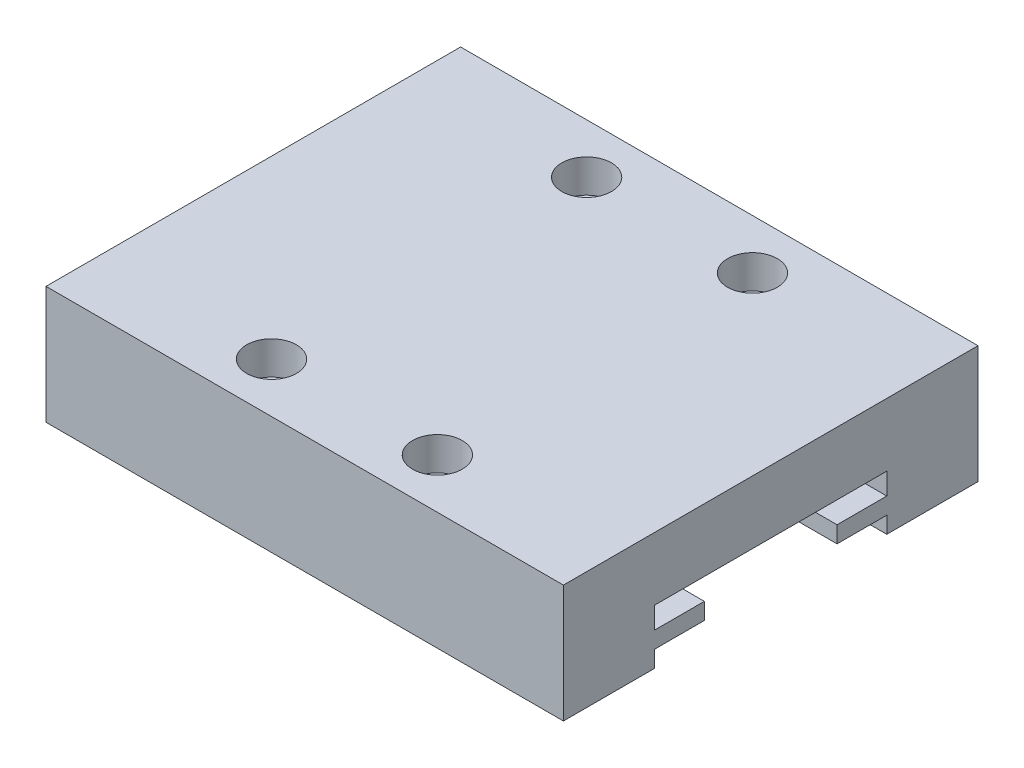
from build123d import *

# Parameters (mm, degrees)
SKETCH_1_W          = 31.2
SKETCH_1_H          = 25
EXTRUDE_1_DEPTH     = 7.1
CUT_EXTRUDE_1_DEPTH = 50.9
SKETCH_3_R          = 1.5
CUT_EXTRUDE_9_DEPTH = 2


with BuildPart() as part:
    # 草图1 → 凸台-拉伸1 (new body)
    with BuildSketch(Plane(origin=(0, 0, 0), x_dir=(1, 0, 0), z_dir=(0, 1, 0))):
        with Locations((15.6, 12.5)):
            Rectangle(SKETCH_1_W, SKETCH_1_H)
    extrude(amount=EXTRUDE_1_DEPTH)

    # 草图2 → 切除-拉伸1 (cut)
    with BuildSketch(Plane.ZY):
        Polygon((-19.5, 0), (-19.5, 1), (-16.5, 1), (-16.5, 2), (-19.5, 2), (-19.5, 3.3), (-12.5, 3.3), (-5.5, 3.3), (-5.5, 2), (-8.5, 2), (-8.5, 1), (-5.5, 1), (-5.5, 0), align=None)
    extrude(amount=-CUT_EXTRUDE_1_DEPTH, mode=Mode.SUBTRACT)

    # 草图3 → 切除-拉伸9 (cut)
    with BuildSketch(Plane(origin=(0, 7.1, 0), x_dir=(1, 0, 0), z_dir=(0, 1, 0))):
        with Locations((10.6, 22)):
            Circle(SKETCH_3_R)
        with Locations((20.6, 22)):
            Circle(SKETCH_3_R)
        with Locations((20.6, 3)):
            Circle(SKETCH_3_R)
        with Locations((10.6, 3)):
            Circle(SKETCH_3_R)
    extrude(amount=-CUT_EXTRUDE_9_DEPTH, mode=Mode.SUBTRACT)


solid = part.part
